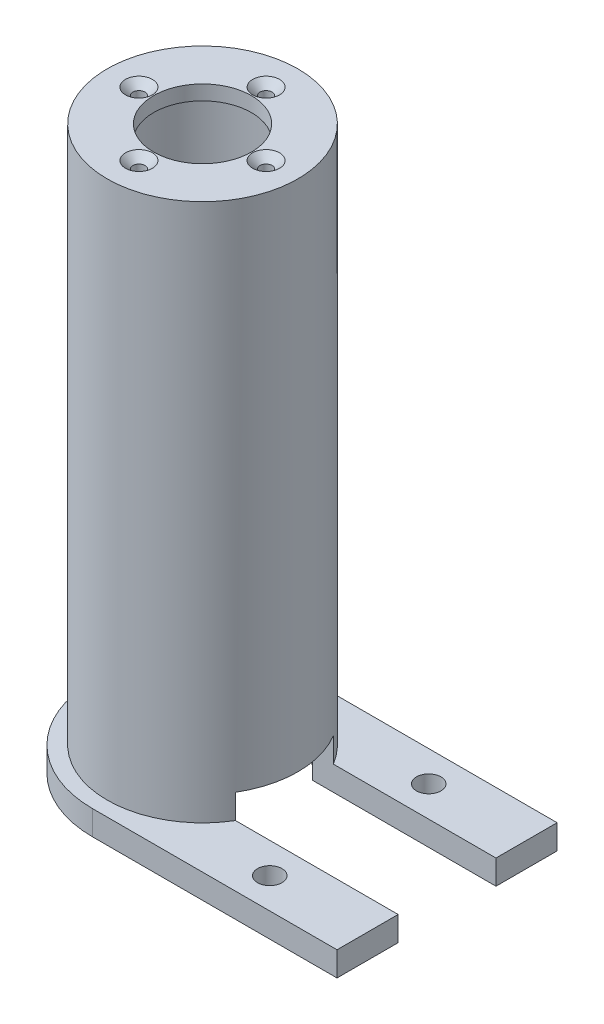
from build123d import *

# Parameters (mm, degrees)
SKETCH1_R                = 19.5
OUTERDIAMETERSTOCK_DEPTH = 115
SCREWONBASE_START        = -115
SCREWONBASE_DEPTH        = 5
INNERDIAMETER_START      = -3
SKETCH2_R                = 16
INNERDIAMETER_DEPTH      = 113
SKETCH3_R                = 10
HOLE_DEPTH               = 116
CUT_EXTRUDE3_REACH       = 117
SKETCH5_R                = 1.25
CHAMFER1_SIZE            = 1.5
WIRESLOT_START           = -115
SKETCH6_W                = 50
SKETCH6_H                = 20
WIRESLOT_DEPTH           = 10
MOUNTING_START           = -115
SKETCH7_R                = 2.5
MOUNTING_HOLES_DEPTH     = 5


with BuildPart() as part:
    # Sketch1 → OuterDiameterStock (new body)
    with BuildSketch(Plane(origin=(0, 0, 0), x_dir=(1, 0, 0), z_dir=(0, 1, 0))):
        Circle(SKETCH1_R)
    extrude(amount=-OUTERDIAMETERSTOCK_DEPTH)

    # Sketch4 → ScrewOnBase (add)
    with BuildSketch(Plane(origin=(0, 0, 0), x_dir=(1, 0, 0), z_dir=(0, 1, 0)).offset(SCREWONBASE_START)):
        with BuildLine():
            Line((0, 22.5), (50, 22.5))
            Line((50, 22.5), (50, -22.5))
            Line((50, -22.5), (0, -22.5))
            ThreePointArc((0, -22.5), (-22.5, 0), (0, 22.5))
        make_face()
    extrude(amount=SCREWONBASE_DEPTH)

    # Sketch2 → InnerDiameter (cut, through all)
    with BuildSketch(Plane(origin=(0, 0, 0), x_dir=(1, 0, 0), z_dir=(0, 1, 0)).offset(INNERDIAMETER_START)):
        Circle(SKETCH2_R)
    extrude(amount=-INNERDIAMETER_DEPTH, mode=Mode.SUBTRACT)

    # Sketch3 → Hole (cut, through all)
    with BuildSketch(Plane(origin=(0, 0, 0), x_dir=(1, 0, 0), z_dir=(0, 1, 0))):
        Circle(SKETCH3_R)
    extrude(amount=-HOLE_DEPTH, mode=Mode.SUBTRACT)

    # Sketch5 → Cut-Extrude3 (cut, up to next)
    with BuildSketch(Plane(origin=(0, 0, 0), x_dir=(1, 0, 0), z_dir=(0, 1, 0)), mode=Mode.PRIVATE) as cut_extrude3_sk1:
        with Locations((0, 13)):
            Circle(SKETCH5_R)
    cut_extrude3_tool1 = extrude(cut_extrude3_sk1.sketch, amount=-CUT_EXTRUDE3_REACH, mode=Mode.PRIVATE) & part.part
    add(cut_extrude3_tool1.solids().sort_by_distance((0, 0, -13))[0], mode=Mode.SUBTRACT)
    # Sketch5 → Cut-Extrude3 (cut, up to next)
    with BuildSketch(Plane(origin=(0, 0, 0), x_dir=(1, 0, 0), z_dir=(0, 1, 0)), mode=Mode.PRIVATE) as cut_extrude3_sk2:
        with Locations((13, 0)):
            Circle(SKETCH5_R)
    cut_extrude3_tool2 = extrude(cut_extrude3_sk2.sketch, amount=-CUT_EXTRUDE3_REACH, mode=Mode.PRIVATE) & part.part
    add(cut_extrude3_tool2.solids().sort_by_distance((13, 0, 0))[0], mode=Mode.SUBTRACT)
    # Sketch5 → Cut-Extrude3 (cut, up to next)
    with BuildSketch(Plane(origin=(0, 0, 0), x_dir=(1, 0, 0), z_dir=(0, 1, 0)), mode=Mode.PRIVATE) as cut_extrude3_sk3:
        with Locations((0, -13)):
            Circle(SKETCH5_R)
    cut_extrude3_tool3 = extrude(cut_extrude3_sk3.sketch, amount=-CUT_EXTRUDE3_REACH, mode=Mode.PRIVATE) & part.part
    add(cut_extrude3_tool3.solids().sort_by_distance((0, 0, 13))[0], mode=Mode.SUBTRACT)
    # Sketch5 → Cut-Extrude3 (cut, up to next)
    with BuildSketch(Plane(origin=(0, 0, 0), x_dir=(1, 0, 0), z_dir=(0, 1, 0)), mode=Mode.PRIVATE) as cut_extrude3_sk4:
        with Locations((-13, 0)):
            Circle(SKETCH5_R)
    cut_extrude3_tool4 = extrude(cut_extrude3_sk4.sketch, amount=-CUT_EXTRUDE3_REACH, mode=Mode.PRIVATE) & part.part
    add(cut_extrude3_tool4.solids().sort_by_distance((-13, 0, 0))[0], mode=Mode.SUBTRACT)

    # Chamfer1
    chamfer1_edges = [part.edges().sort_by_distance(p)[0] for p in [
        (-1.25, 0, -13),
        (11.75, 0, 0),
        (-1.25, 0, 13),
        (-14.25, 0, 0),
    ]]
    chamfer(chamfer1_edges, length=CHAMFER1_SIZE)

    # Sketch6 → WireSlot (cut)
    with BuildSketch(Plane(origin=(0, 0, 0), x_dir=(1, 0, 0), z_dir=(0, 1, 0)).offset(WIRESLOT_START)):
        with Locations((25, 0)):
            Rectangle(SKETCH6_W, SKETCH6_H)
    extrude(amount=WIRESLOT_DEPTH, mode=Mode.SUBTRACT)

    # Sketch7 → Mounting Holes (cut)
    with BuildSketch(Plane(origin=(0, 0, 0), x_dir=(1, 0, 0), z_dir=(0, 1, 0)).offset(MOUNTING_START)):
        with Locations((30, 16.25)):
            Circle(SKETCH7_R)
        with Locations((30, -16.25)):
            Circle(SKETCH7_R)
    extrude(amount=MOUNTING_HOLES_DEPTH, mode=Mode.SUBTRACT)


solid = part.part
